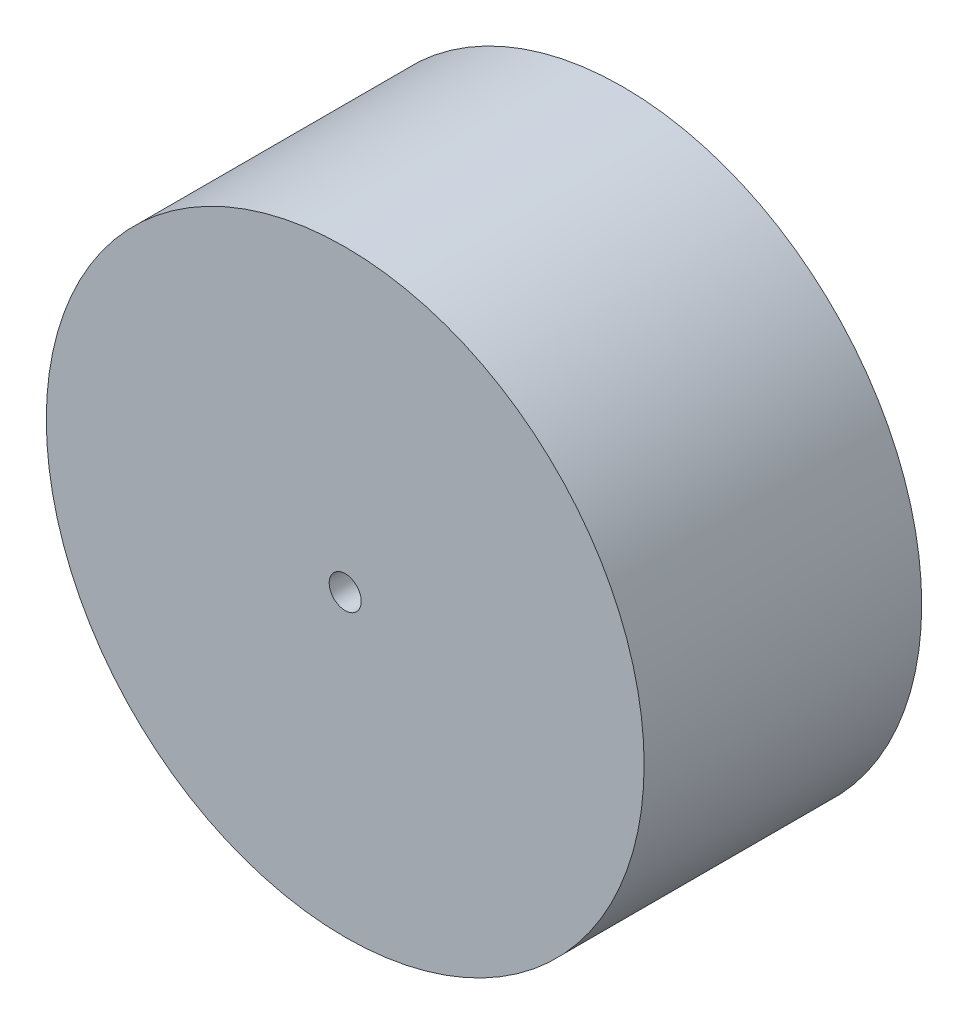
from build123d import *

# Parameters (mm, degrees)
SKETCH_1_R      = 28
SKETCH_1_R_2    = 1.5
EXTRUDE_1_DEPTH = 26


with BuildPart() as part:
    # 草圖1 → 填料-伸長1 (new body)
    with BuildSketch(Plane.XY):
        Circle(SKETCH_1_R)
        Circle(SKETCH_1_R_2, mode=Mode.SUBTRACT)
    extrude(amount=EXTRUDE_1_DEPTH)


solid = part.part
